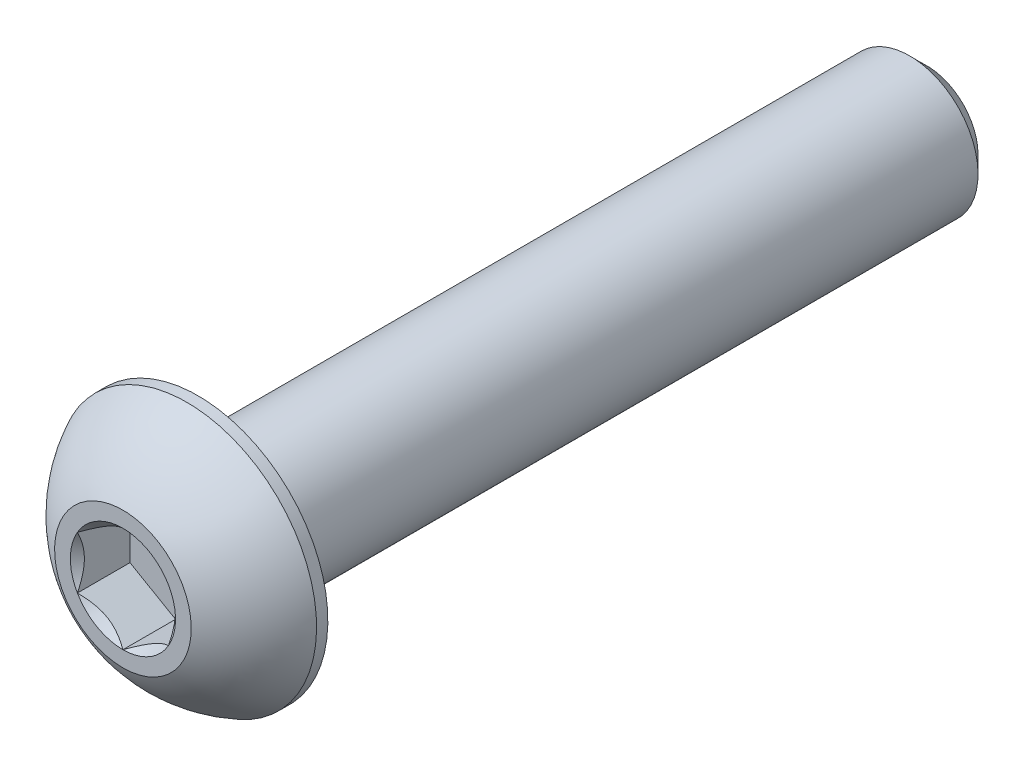
from build123d import *

# Parameters (mm, degrees)
CUT_EXTRUDE2_DEPTH = 1.155


with BuildPart() as part:
    # Sketch10 → Revolve3 (revolve)
    with BuildSketch(Plane(origin=(0, 0, 0), x_dir=(0, 0, -1), z_dir=(1, 0, 0))):
        Polygon((7.625, 1.5), (8, 1.125), (8, 0), (-8, 0), (-8, 1.5), align=None)
    revolve(axis=Axis((0, 0, 9.65), (0, 0, -1)))

    # Sketch7 → Revolve2 (revolve)
    with BuildSketch(Plane(origin=(0, 0, 0), x_dir=(0, 0, -1), z_dir=(1, 0, 0))):
        with BuildLine():
            Line((-8.2475, 2.85), (-8, 2.85))
            Line((-8, 2.85), (-8, 0))
            Line((-8, 0), (-9.65, 0))
            Line((-9.65, 0), (-9.65, 1.5))
            ThreePointArc((-9.65, 1.5), (-9.05487489, 2.285251969), (-8.2475, 2.85))
        make_face()
    revolve(axis=Axis((0, 0, 9.65), (0, 0, -1)))

    # Sketch5 → Cut-Extrude2 (cut)
    with BuildSketch(Plane.XY.offset(9.65)):
        Polygon((1, -0.577350269), (1, 0.577350269), (0, 1.154700538), (-1, 0.577350269), (-1, -0.577350269), (0, -1.154700538), align=None)
    extrude(amount=-CUT_EXTRUDE2_DEPTH, mode=Mode.SUBTRACT)

    # Cut-Extrude3 cone 1 section (through the dimple's axis) → Cut-Extrude3 (revolve, cut)
    with BuildSketch(Plane(origin=(0, 0, 9.65), x_dir=(0, -1, 0), z_dir=(1, 0, 0))):
        Polygon((0, 0), (1.154700538, 0), (0, 1.154700538), align=None)
    revolve(axis=Axis((0, 0, 9.65), (0, 0, -1)), mode=Mode.SUBTRACT)


solid = part.part
